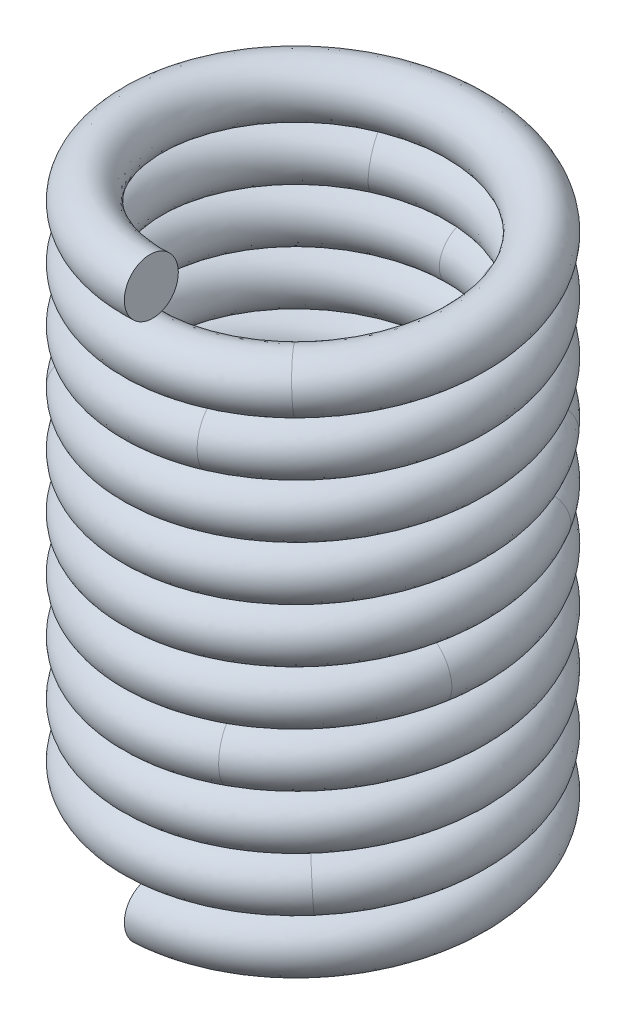
from build123d import *

# Parameters (mm, degrees)
SWEEP2_PITCH  = 5
SWEEP2_HEIGHT = 50
SWEEP2_RADIUS = 15
SKETCH4_R     = 2.5


with BuildPart() as part:
    # Sweep2: sweep along a helix
    with BuildLine() as sweep2_path:
        Helix(SWEEP2_PITCH, SWEEP2_HEIGHT, SWEEP2_RADIUS, center=(0, 0, 0), direction=(0, 1, 0))
    # Sketch4 → Sweep2 (sweep)
    with BuildSketch(Plane(origin=(0, 0, 15), x_dir=(0, 0, -1), z_dir=(0.998595725, 0.052977149, 0))):
        Circle(SKETCH4_R)
    sweep(path=sweep2_path.line, is_frenet=True)


solid = part.part
